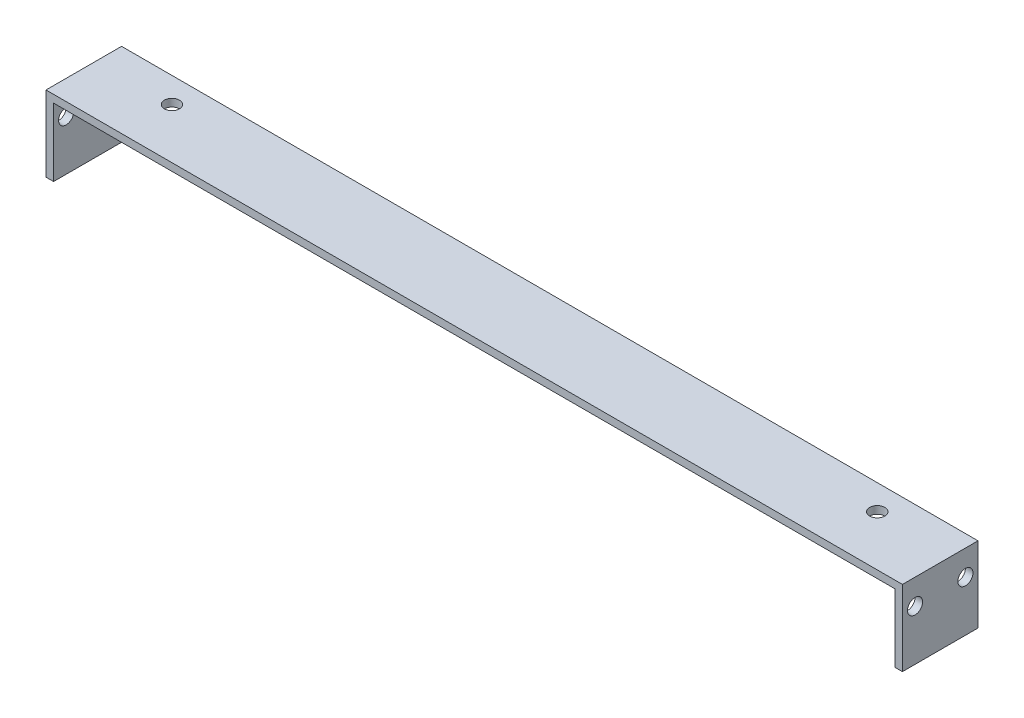
from build123d import *

# Parameters (mm, degrees)
SKETCH1_W               = 167
SKETCH1_H               = 15
BOSS_EXTRUDE1_DEPTH     = 1.5
SKETCH2_W               = 15
SKETCH2_H               = 15
BOSS_EXTRUDE2_DEPTH     = 1.5
SKETCH3_W               = 15
SKETCH3_H               = 15
BOSS_EXTRUDE3_DEPTH     = 1.5
CUT_EXTRUDE1_DEPTH      = 1000
CUT_EXTRUDE1_DEPTH_BACK = 10000
SKETCH5_R               = 1.5
CUT_EXTRUDE2_DEPTH      = 10000
CUT_EXTRUDE2_DEPTH_BACK = 10000
SKETCH4_R               = 1.5


with BuildPart() as part:
    # Sketch1 → Boss-Extrude1 (new body)
    with BuildSketch(Plane(origin=(0, 0, 0), x_dir=(1, 0, 0), z_dir=(0, 1, 0))):
        with Locations((83.5, 7.5)):
            Rectangle(SKETCH1_W, SKETCH1_H)
    extrude(amount=BOSS_EXTRUDE1_DEPTH)

    # Sketch2 → Boss-Extrude2 (add)
    with BuildSketch(Plane(origin=(167, 0, 0), x_dir=(0, 0, -1), z_dir=(1, 0, 0))):
        with Locations((7.5, -6)):
            Rectangle(SKETCH2_W, SKETCH2_H)
    extrude(amount=BOSS_EXTRUDE2_DEPTH)

    # Sketch3 → Boss-Extrude3 (add)
    with BuildSketch(Plane.ZY):
        with Locations((-7.5, -6)):
            Rectangle(SKETCH3_W, SKETCH3_H)
    extrude(amount=BOSS_EXTRUDE3_DEPTH)

    # Sketch5 → Cut-Extrude1 (cut, two sides: drawn at the far end of the back side and taken through both)
    with BuildSketch(Plane(origin=(168.5, 0, 0), x_dir=(0, 0, -1), z_dir=(1, 0, 0)).offset(-CUT_EXTRUDE1_DEPTH_BACK)):
        with Locations((2.5, -3.5)):
            Circle(SKETCH5_R)
        with Locations((12.5, -3.5)):
            Circle(SKETCH5_R)
    extrude(amount=CUT_EXTRUDE1_DEPTH + CUT_EXTRUDE1_DEPTH_BACK, mode=Mode.SUBTRACT)

    # Sketch4 → Cut-Extrude2 (cut, two sides: drawn at the far end of the back side and taken through both)
    with BuildSketch(Plane(origin=(0, 1.5, 0), x_dir=(1, 0, 0), z_dir=(0, 1, 0)).offset(-CUT_EXTRUDE2_DEPTH_BACK)):
        with Locations((13.5, 10)):
            Circle(SKETCH4_R)
        with Locations((153.5, 10)):
            Circle(SKETCH4_R)
    extrude(amount=CUT_EXTRUDE2_DEPTH + CUT_EXTRUDE2_DEPTH_BACK, mode=Mode.SUBTRACT)


solid = part.part
